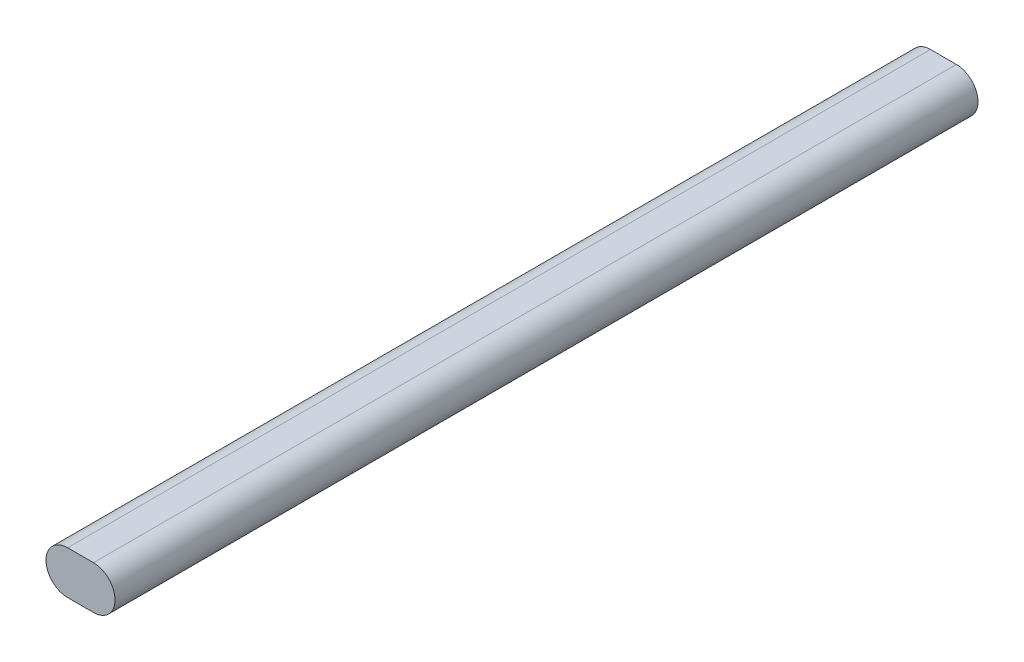
from build123d import *

# Parameters (mm, degrees)
BOSS_EXTRUDE1_DEPTH = 500


with BuildPart() as part:
    # Sketch1 → Boss-Extrude1 (new body)
    with BuildSketch(Plane.XY):
        with BuildLine():
            Line((-7.5, 12.5), (7.5, 12.5))
            ThreePointArc((7.5, 12.5), (20, 0), (7.5, -12.5))
            Line((7.5, -12.5), (-7.5, -12.5))
            ThreePointArc((-7.5, -12.5), (-20, 0), (-7.5, 12.5))
        make_face()
    extrude(amount=BOSS_EXTRUDE1_DEPTH)


solid = part.part
